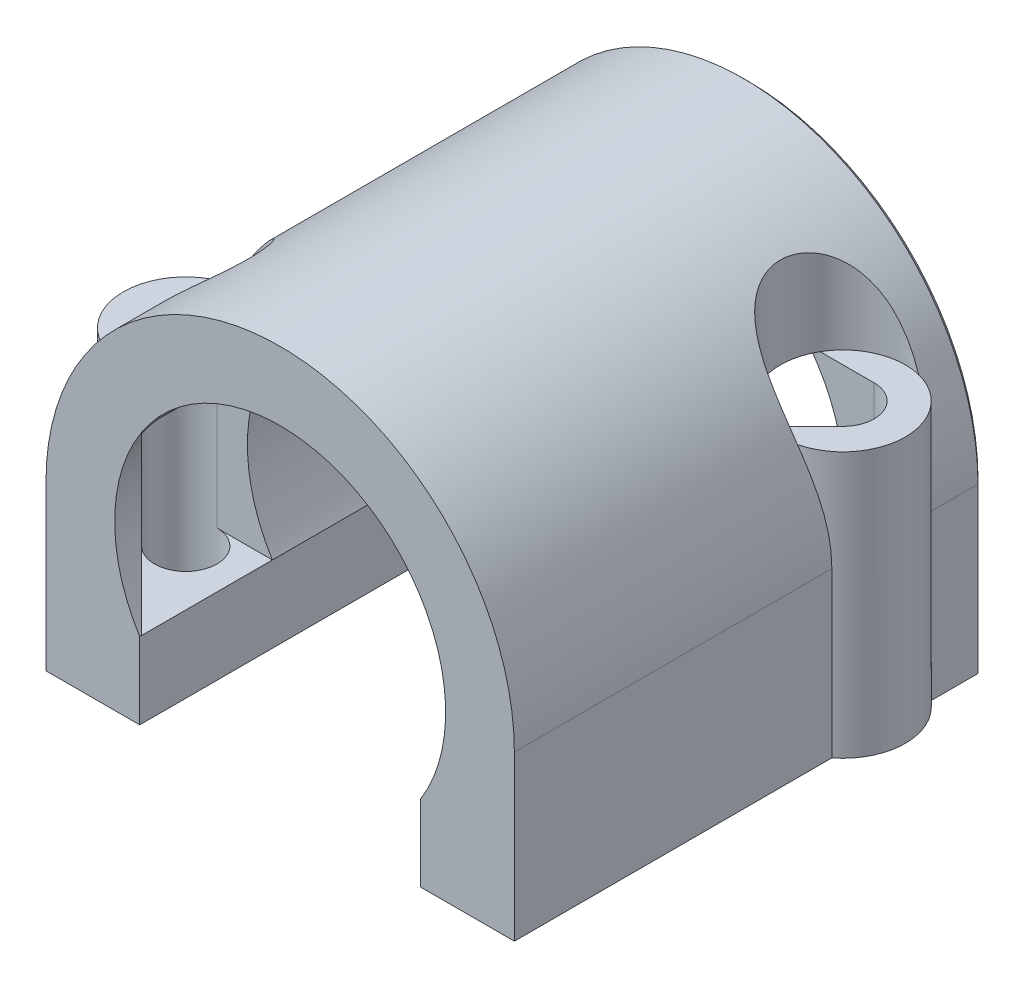
from build123d import *

# Parameters (mm, degrees)
BOSS_EXTRUDE1_DEPTH     = 30
BOSS_EXTRUDE2_DEPTH     = 17
SKETCH2_R               = 2
CUT_EXTRUDE7_DEPTH      = 26.5000001
CUT_EXTRUDE2_START      = -17
SKETCH3_R               = 4
CUT_EXTRUDE2_DEPTH      = 9.5000001
CUT_EXTRUDE3_DEPTH      = 31.0000001
CUT_EXTRUDE8_DEPTH      = 6.5
CUT_EXTRUDE8_DEPTH_BACK = 5.6
CHAMFER1_SIZE           = 0.3


with BuildPart() as part:
    # Sketch1 → Boss-Extrude1 (new body)
    with BuildSketch(Plane.XY):
        with BuildLine():
            Line((-9, -10.5), (9, -10.5))
            Line((9, -10.5), (15, -10.5))
            Line((15, -10.5), (15, 0))
            ThreePointArc((15, 0), (0, 15), (-15, 0))
            Line((-15, 0), (-15, -10.5))
            Line((-15, -10.5), (-9, -10.5))
        make_face()
    extrude(amount=BOSS_EXTRUDE1_DEPTH)

    # Sketch4 → Boss-Extrude2 (add)
    with BuildSketch(Plane.XZ.offset(10.5)):
        with BuildLine():
            Line((-12.55, 27.5), (-12.55, 19.5))
            ThreePointArc((-12.55, 19.5), (-16.55, 23.5), (-12.55, 27.5))
        make_face()
        with BuildLine():
            Line((12.55, 2.5), (12.55, 10.5))
            ThreePointArc((12.55, 10.5), (16.55, 6.5), (12.55, 2.5))
        make_face()
    extrude(amount=-BOSS_EXTRUDE2_DEPTH)

    # Sketch2 → Cut-Extrude7 (cut, through all)
    with BuildSketch(Plane.XZ.offset(10.5)):
        with Locations((12.55, 6.5)):
            Circle(SKETCH2_R)
        with Locations((-12.55, 23.5)):
            Circle(SKETCH2_R)
    extrude(amount=-CUT_EXTRUDE7_DEPTH, mode=Mode.SUBTRACT)

    # Sketch3 → Cut-Extrude2 (cut, through all)
    with BuildSketch(Plane.XZ.offset(10.5).offset(CUT_EXTRUDE2_START)):
        with Locations((12.55, 6.5)):
            Circle(SKETCH3_R)
        with Locations((-12.55, 23.5)):
            Circle(SKETCH3_R)
    extrude(amount=-CUT_EXTRUDE2_DEPTH, mode=Mode.SUBTRACT)

    # Sketch5 → Cut-Extrude3 (cut, through all)
    with BuildSketch(Plane.XY.offset(30)):
        with BuildLine():
            Line((-9, -10.5), (9, -10.5))
            Line((9, -10.5), (9, -5.6))
            ThreePointArc((9, -5.6), (0, 10.6), (-9, -5.6))
            Line((-9, -5.6), (-9, -10.5))
        make_face()
    extrude(amount=-CUT_EXTRUDE3_DEPTH, mode=Mode.SUBTRACT)

    # Sketch6 → Cut-Extrude8 (cut, two sides)
    with BuildSketch(Plane(origin=(0, 0, 0), x_dir=(1, 0, 0), z_dir=(0, 1, 0))) as cut_extrude8_sk:
        Polygon((0, -24.914213562), (0, -21.5), (-12.55, -21.5), (-13.964213562, -24.914213562), (-9, -29.878427125), align=None)
        Polygon((0, -7.914213562), (0, -4.5), (12.55, -4.5), (13.964213562, -7.914213562), (9, -12.878427125), align=None)
    extrude(amount=CUT_EXTRUDE8_DEPTH, mode=Mode.SUBTRACT)
    extrude(cut_extrude8_sk.sketch, amount=-CUT_EXTRUDE8_DEPTH_BACK, mode=Mode.SUBTRACT)

    # Chamfer1
    chamfer1_edges = [part.edges().sort_by_distance(p)[0] for p in [
        (0, 15, 0),
        (15, -5.25, 0),
        (-12, -10.5, 0),
        (-15, -5.25, 0),
        (12, -10.5, 0),
        (0, 10.6, 0),
        (9, -8.05, 0),
        (-9, -8.05, 0),
    ]]
    chamfer(chamfer1_edges, length=CHAMFER1_SIZE)


solid = part.part
